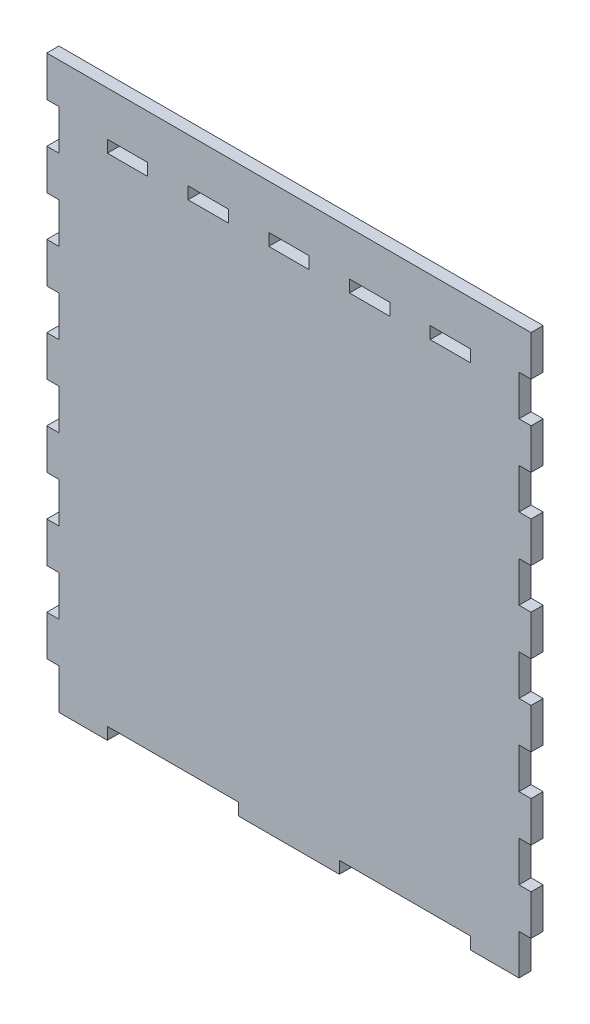
from build123d import *

# Parameters (mm, degrees)
SKETCH1_W           = 240
SKETCH1_H           = 280
BOSS_EXTRUDE1_DEPTH = 6
SKETCH3_W           = 6
SKETCH3_H           = 20
CUT_EXTRUDE1_DEPTH  = 6
SKETCH4_W           = 6
SKETCH4_H           = 20
SKETCH4_W_2         = 65
SKETCH4_H_2         = 6
CUT_EXTRUDE2_DEPTH  = 6
SKETCH5_W           = 20
SKETCH5_H           = 6
CUT_EXTRUDE3_DEPTH  = 6


with BuildPart() as part:
    # Sketch1 → Boss-Extrude1 (new body)
    with BuildSketch(Plane.XY):
        Rectangle(SKETCH1_W, SKETCH1_H)
    extrude(amount=-BOSS_EXTRUDE1_DEPTH)

    # Sketch3 → Cut-Extrude1 (cut)
    with BuildSketch(Plane.XY):
        with Locations((117, 110)):
            Rectangle(SKETCH3_W, SKETCH3_H)
        with Locations((117, 70)):
            Rectangle(SKETCH3_W, SKETCH3_H)
        with Locations((117, 30)):
            Rectangle(SKETCH3_W, SKETCH3_H)
        with Locations((117, -10)):
            Rectangle(SKETCH3_W, SKETCH3_H)
        with Locations((117, -50)):
            Rectangle(SKETCH3_W, SKETCH3_H)
        with Locations((-117, 110)):
            Rectangle(SKETCH3_W, SKETCH3_H)
        with Locations((-117, 70)):
            Rectangle(SKETCH3_W, SKETCH3_H)
        with Locations((-117, 30)):
            Rectangle(SKETCH3_W, SKETCH3_H)
        with Locations((-117, -10)):
            Rectangle(SKETCH3_W, SKETCH3_H)
        with Locations((-117, -50)):
            Rectangle(SKETCH3_W, SKETCH3_H)
        with Locations((117, -90)):
            Rectangle(SKETCH3_W, SKETCH3_H)
        with Locations((-117, -90)):
            Rectangle(SKETCH3_W, SKETCH3_H)
    extrude(amount=-CUT_EXTRUDE1_DEPTH, mode=Mode.SUBTRACT)

    # Sketch4 → Cut-Extrude2 (cut)
    with BuildSketch(Plane.XY):
        with Locations((117, -130)):
            Rectangle(SKETCH4_W, SKETCH4_H)
        with Locations((57.5, -137)):
            Rectangle(SKETCH4_W_2, SKETCH4_H_2)
        with Locations((-57.5, -137)):
            Rectangle(SKETCH4_W_2, SKETCH4_H_2)
        with Locations((-117, -130)):
            Rectangle(SKETCH4_W, SKETCH4_H)
    extrude(amount=-CUT_EXTRUDE2_DEPTH, mode=Mode.SUBTRACT)

    # Sketch5 → Cut-Extrude3 (cut)
    with BuildSketch(Plane.XY):
        with Locations((0, 115)):
            Rectangle(SKETCH5_W, SKETCH5_H)
        with Locations((-80, 115)):
            Rectangle(SKETCH5_W, SKETCH5_H)
        with Locations((40, 115)):
            Rectangle(SKETCH5_W, SKETCH5_H)
        with Locations((80, 115)):
            Rectangle(SKETCH5_W, SKETCH5_H)
        with Locations((-40, 115)):
            Rectangle(SKETCH5_W, SKETCH5_H)
    extrude(amount=-CUT_EXTRUDE3_DEPTH, mode=Mode.SUBTRACT)


solid = part.part
